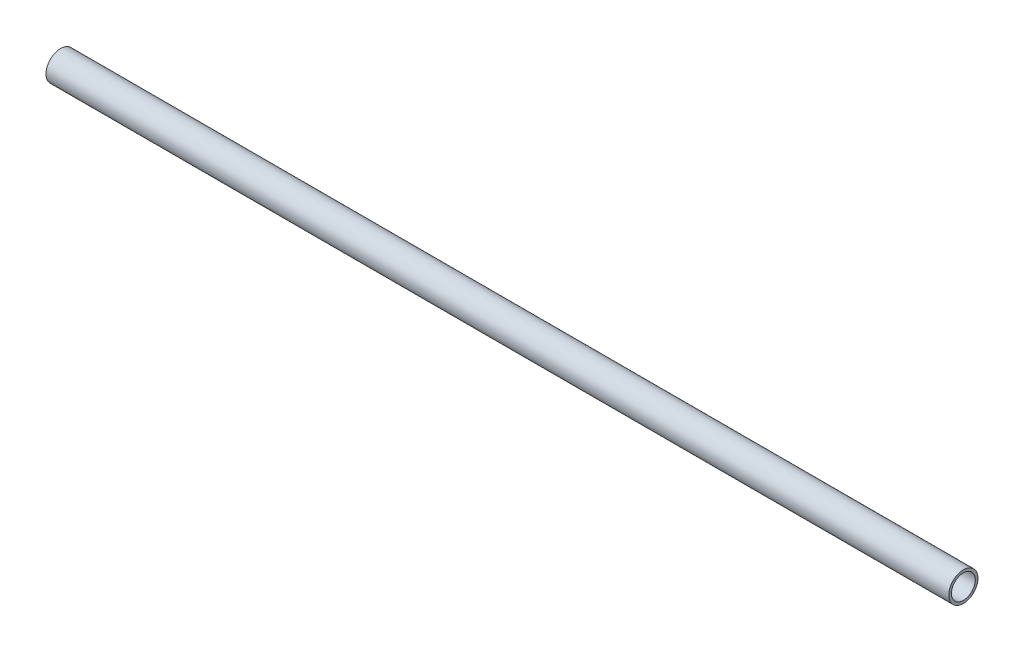
from build123d import *

# Parameters (mm, degrees)
SKETCH11_R               = 7.9375
SKETCH11_R_2             = 6.4643
STRUCTURAL_MEMBER1_DEPTH = 489.896


with BuildPart() as part:
    # Sketch11 → Structural Member1 (new body)
    with BuildSketch(Plane(origin=(-489.896, 0, 0), x_dir=(0, 0, -1), z_dir=(1, 0, 0))):
        Circle(SKETCH11_R)
        Circle(SKETCH11_R_2, mode=Mode.SUBTRACT)
    extrude(amount=STRUCTURAL_MEMBER1_DEPTH)


solid = part.part
